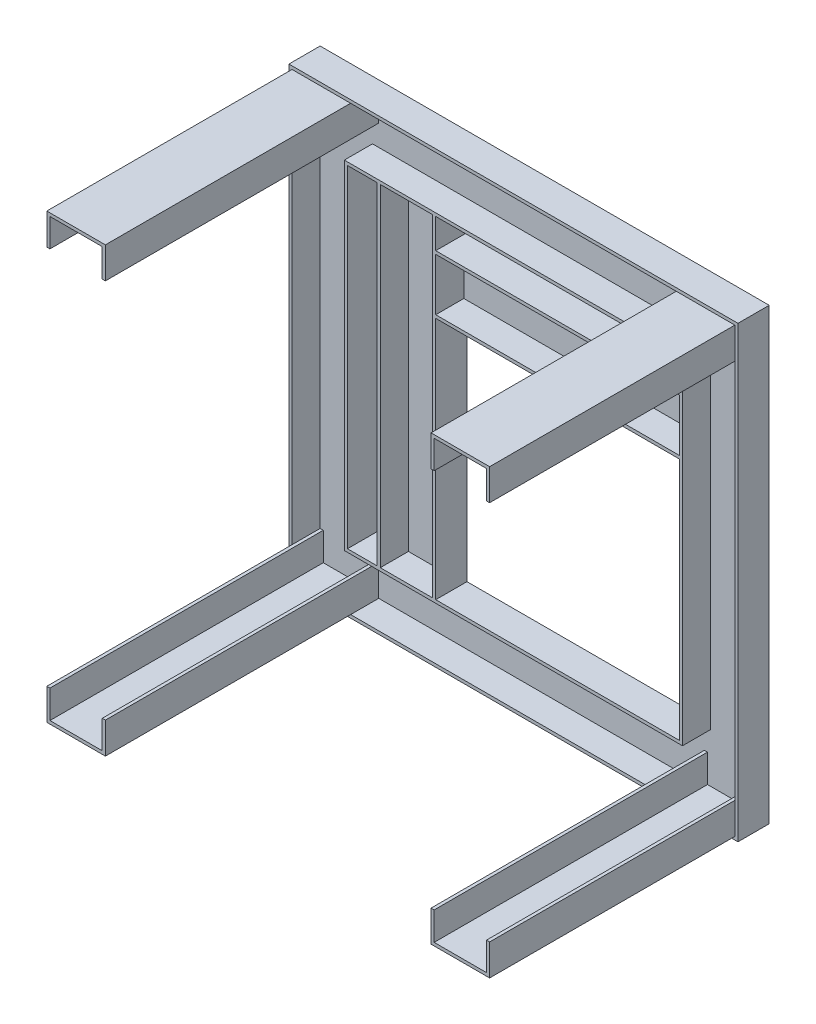
from build123d import *

# Parameters (mm, degrees)
BOSS_EXTRUDE1_DEPTH  = 350
LPATTERN1_COUNT      = 2
LPATTERN1_PITCH      = 492
MIRROR1_COPY_1_DEPTH = 350
MIRROR1_COPY_2_DEPTH = 350


with BuildPart() as part:
    # Sweep1: sweep along a path in Sketch1
    with BuildLine(Plane.XY) as sweep1_path:
        Line((-250, -250), (250, -250))
        Line((250, -250), (250, 250))
        Line((250, 250), (-250, 250))
        Line((-250, 250), (-250, -250))
    # Sketch2 → Sweep1 (sweep)
    with BuildSketch(Plane(origin=(0, -250, 0), x_dir=(1, 0, 0), z_dir=(0, 1, 0))):
        Polygon((212.5, 2), (287.5, 2), (287.5, -38), (283.5, -38), (283.5, -2), (216.5, -2), (216.5, -38), (212.5, -38), align=None)
    sweep(path=sweep1_path.line, transition=Transition.RIGHT)

    # Sweep3: sweep along a path in Sketch4
    with BuildLine(Plane.XY) as sweep3_path:
        Line((-137, 212.5), (-137, -212.5))
    # Sketch5 → Sweep3 (sweep)
    with BuildSketch(Plane(origin=(0, -212.5, 0), x_dir=(1, 0, 0), z_dir=(0, 1, 0))):
        Polygon((-174.5, 2), (-99.5, 2), (-99.5, -38), (-103.5, -38), (-103.5, -2), (-170.5, -2), (-170.5, -38), (-174.5, -38), align=None)
    sweep(path=sweep3_path.line)

    # Sweep4: sweep along a path in Sketch6
    with BuildLine(Plane.XY) as sweep4_path:
        Line((212.5, 137), (-99.5, 137))
    # Sketch7 → Sweep4 (sweep)
    with BuildSketch(Plane.ZY.offset(-212.5)):
        Polygon((-2, 99.5), (-2, 174.5), (38, 174.5), (38, 170.5), (2, 170.5), (2, 103.5), (38, 103.5), (38, 99.5), align=None)
    sweep(path=sweep4_path.line)

    # Sketch8 → Boss-Extrude1 (add)
    with BuildSketch(Plane.XY.offset(2)):
        Polygon((-283.5, 283.5), (-208.5, 283.5), (-208.5, 243.5), (-212.5, 243.5), (-212.5, 279.5), (-279.5, 279.5), (-279.5, 243.5), (-283.5, 243.5), align=None)
    boss_extrude1 = extrude(amount=BOSS_EXTRUDE1_DEPTH)

    # LPattern1: Boss-Extrude1 ×2
    with Locations(*[(i * LPATTERN1_PITCH, 0, 0) for i in range(1, LPATTERN1_COUNT)]):
        add(boss_extrude1)

    # Mirror1 copy 1 sketch → Mirror1 copy 1 (add)
    with BuildSketch(Plane(origin=(492, 0, 2), x_dir=(1, 0, 0), z_dir=(0, 0, 1))):
        Polygon((-283.5, -283.5), (-208.5, -283.5), (-208.5, -243.5), (-212.5, -243.5), (-212.5, -279.5), (-279.5, -279.5), (-279.5, -243.5), (-283.5, -243.5), align=None)
    extrude(amount=MIRROR1_COPY_1_DEPTH)

    # Mirror1 copy 2 sketch → Mirror1 copy 2 (add)
    with BuildSketch(Plane.XY.offset(2)):
        Polygon((-283.5, -283.5), (-208.5, -283.5), (-208.5, -243.5), (-212.5, -243.5), (-212.5, -279.5), (-279.5, -279.5), (-279.5, -243.5), (-283.5, -243.5), align=None)
    extrude(amount=MIRROR1_COPY_2_DEPTH)


solid = part.part
